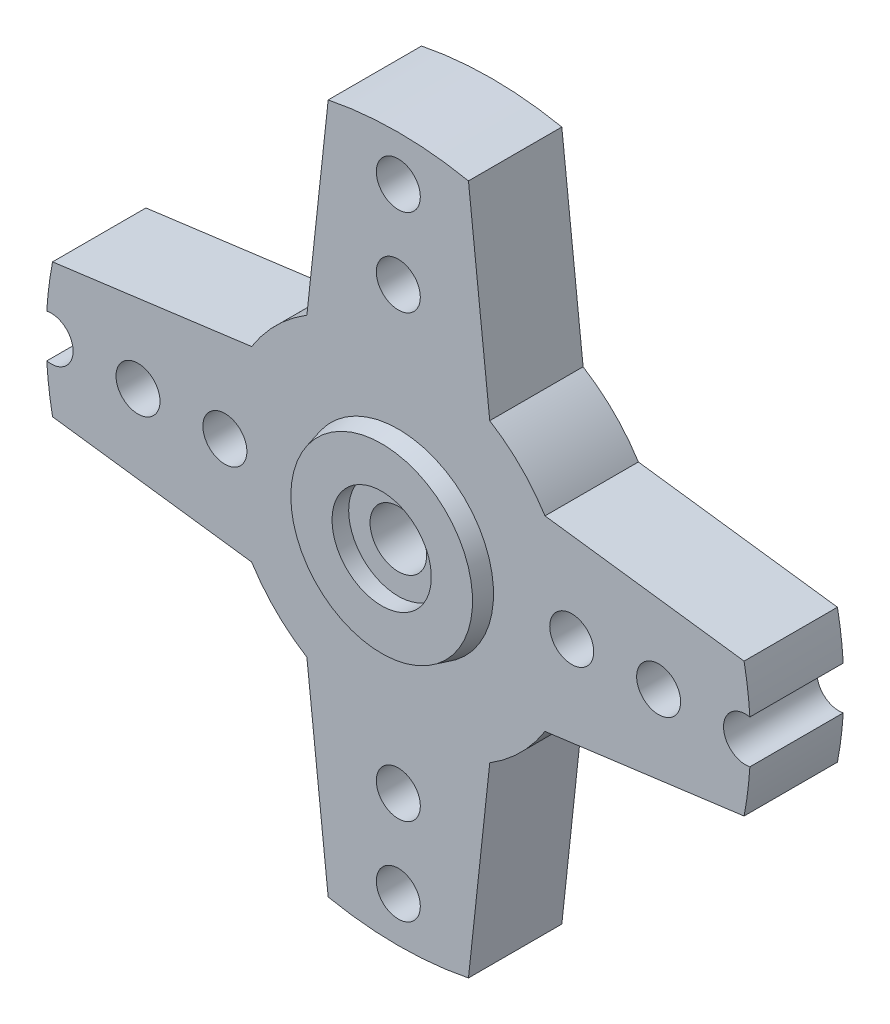
from build123d import *

# Parameters (mm, degrees)
SKETCH1_R                 = 5.98
BOSS_EXTRUDE1_DEPTH       = 1.15
BOSS_EXTRUDE2_DEPTH       = 5.05
F_3_0MM_DOWEL_HOLE1_D     = 3.06
F_3_0MM_DOWEL_HOLE1_DEPTH = 15
F_3_0MM_DOWEL_HOLE1_TIP   = 0.919316747
SKETCH6_R                 = 0.25
CUT_EXTRUDE1_DEPTH        = 3.96
SKETCH7_R                 = 2.675
CUT_EXTRUDE2_DEPTH        = 3.96
SKETCH8_R                 = 1.19
CUT_EXTRUDE3_DEPTH        = 8.35
SKETCH9_OUTSIDE_W         = 70.76
SKETCH9_OUTSIDE_H         = 75.83
SKETCH9_OUTSIDE_R         = 19.05
CUT_EXTRUDE4_DEPTH        = 8.35


with BuildPart() as part:
    # Sketch1 → Boss-Extrude1 (new body, symmetric)
    with BuildSketch(Plane.XY):
        Circle(SKETCH1_R)
    extrude(amount=BOSS_EXTRUDE1_DEPTH, both=True)

    # Sketch2 → Boss-Extrude2 (add)
    with BuildSketch(Plane.XY.offset(1.15)):
        with BuildLine():
            Line((-3, 26.015), (-4.945, 8.011816273))
            ThreePointArc((-4.945, 8.011816273), (-6.609281124, 6.70087173), (-7.933478152, 5.047115555))
            Line((-7.933478152, 5.047115555), (-23.48, 3))
            ThreePointArc((-23.48, 3), (-26.48, 0), (-23.48, -3))
            Line((-23.48, -3), (-7.933478152, -5.047115555))
            ThreePointArc((-7.933478152, -5.047115555), (-6.609281124, -6.70087173), (-4.945, -8.011816273))
            Line((-4.945, -8.011816273), (-3, -26.015))
            ThreePointArc((-3, -26.015), (0, -29.015), (3, -26.015))
            Line((3, -26.015), (4.945, -8.011816273))
            ThreePointArc((4.945, -8.011816273), (6.609281124, -6.70087173), (7.933478152, -5.047115555))
            Line((7.933478152, -5.047115555), (23.48, -3))
            ThreePointArc((23.48, -3), (26.48, 0), (23.48, 3))
            Line((23.48, 3), (7.933478152, 5.047115555))
            ThreePointArc((7.933478152, 5.047115555), (6.609281124, 6.70087173), (4.945, 8.011816273))
            Line((4.945, 8.011816273), (3, 26.015))
            ThreePointArc((3, 26.015), (0, 29.015), (-3, 26.015))
        make_face()
    extrude(amount=BOSS_EXTRUDE2_DEPTH)

    # Ø3.0mm Dowel Hole1
    with Locations(Plane.XY.offset(6.2)):
        with Locations((0, 0)):
            Hole(F_3_0MM_DOWEL_HOLE1_D / 2, depth=F_3_0MM_DOWEL_HOLE1_DEPTH)
            with Locations((0, 0, -(F_3_0MM_DOWEL_HOLE1_DEPTH + F_3_0MM_DOWEL_HOLE1_TIP / 2))):  # 118° drill point
                Cone(0, F_3_0MM_DOWEL_HOLE1_D / 2, F_3_0MM_DOWEL_HOLE1_TIP, mode=Mode.SUBTRACT)

    # Sketch5 → Revolve1 (revolve)
    with BuildSketch(Plane(origin=(0, 0, 0), x_dir=(1, 0, 0), z_dir=(0, 1, 0))):
        Polygon((2.685, -6.2), (2.685, -7.1), (4.915, -7.1), (5.15, -6.2), align=None)
    revolve(axis=Axis((0, 0, -17.732106559), (0, 0, 1)))

    # Sketch6 → Cut-Extrude1 (cut)
    with BuildSketch(Plane(origin=(0, 0, -1.15), x_dir=(-1, 0, 0), z_dir=(0, 0, -1))):
        with Locations((0, 2.675)):
            Circle(SKETCH6_R)
        with Locations((0.914903883, 2.513677761)):
            Circle(SKETCH6_R)
        with Locations((1.719456856, 2.049168885)):
            Circle(SKETCH6_R)
        with Locations((2.316617955, 1.3375)):
            Circle(SKETCH6_R)
        with Locations((2.634360739, 0.464508875)):
            Circle(SKETCH6_R)
        with Locations((2.634360739, -0.464508875)):
            Circle(SKETCH6_R)
        with Locations((2.316617955, -1.3375)):
            Circle(SKETCH6_R)
        with Locations((1.719456856, -2.049168885)):
            Circle(SKETCH6_R)
        with Locations((0.914903883, -2.513677761)):
            Circle(SKETCH6_R)
        with Locations((0, -2.675)):
            Circle(SKETCH6_R)
        with Locations((-0.914903883, -2.513677761)):
            Circle(SKETCH6_R)
        with Locations((-1.719456856, -2.049168885)):
            Circle(SKETCH6_R)
        with Locations((-2.316617955, -1.3375)):
            Circle(SKETCH6_R)
        with Locations((-2.634360739, -0.464508875)):
            Circle(SKETCH6_R)
        with Locations((-2.634360739, 0.464508875)):
            Circle(SKETCH6_R)
        with Locations((-2.316617955, 1.3375)):
            Circle(SKETCH6_R)
        with Locations((-1.719456856, 2.049168885)):
            Circle(SKETCH6_R)
        with Locations((-0.914903883, 2.513677761)):
            Circle(SKETCH6_R)
    extrude(amount=-CUT_EXTRUDE1_DEPTH, mode=Mode.SUBTRACT)

    # Sketch7 → Cut-Extrude2 (cut)
    with BuildSketch(Plane(origin=(0, 0, -1.15), x_dir=(-1, 0, 0), z_dir=(0, 0, -1))):
        Circle(SKETCH7_R)
    extrude(amount=-CUT_EXTRUDE2_DEPTH, mode=Mode.SUBTRACT)

    # Sketch8 → Cut-Extrude3 (cut, through all)
    with BuildSketch(Plane.XY.offset(6.2)):
        with Locations((0, 11.915)):
            Circle(SKETCH8_R)
        with Locations((0, 16.615)):
            Circle(SKETCH8_R)
        with Locations((0, 21.315)):
            Circle(SKETCH8_R)
        with Locations((0, 26.015)):
            Circle(SKETCH8_R)
        with Locations((0, -26.015)):
            Circle(SKETCH8_R)
        with Locations((0, -21.315)):
            Circle(SKETCH8_R)
        with Locations((0, -16.615)):
            Circle(SKETCH8_R)
        with Locations((0, -11.915)):
            Circle(SKETCH8_R)
        with Locations((-23.48, 0)):
            Circle(SKETCH8_R)
        with Locations((-18.78, 0)):
            Circle(SKETCH8_R)
        with Locations((-14.08, 0)):
            Circle(SKETCH8_R)
        with Locations((-9.38, 0)):
            Circle(SKETCH8_R)
        with Locations((9.38, 0)):
            Circle(SKETCH8_R)
        with Locations((14.08, 0)):
            Circle(SKETCH8_R)
        with Locations((18.78, 0)):
            Circle(SKETCH8_R)
        with Locations((23.48, 0)):
            Circle(SKETCH8_R)
    extrude(amount=-CUT_EXTRUDE3_DEPTH, mode=Mode.SUBTRACT)

    # Sketch9 outside → Cut-Extrude4 (cut, through all)
    with BuildSketch(Plane.XY.offset(6.2)):
        Rectangle(SKETCH9_OUTSIDE_W, SKETCH9_OUTSIDE_H)
        Circle(SKETCH9_OUTSIDE_R, mode=Mode.SUBTRACT)
    extrude(amount=-CUT_EXTRUDE4_DEPTH, mode=Mode.SUBTRACT)


solid = part.part
